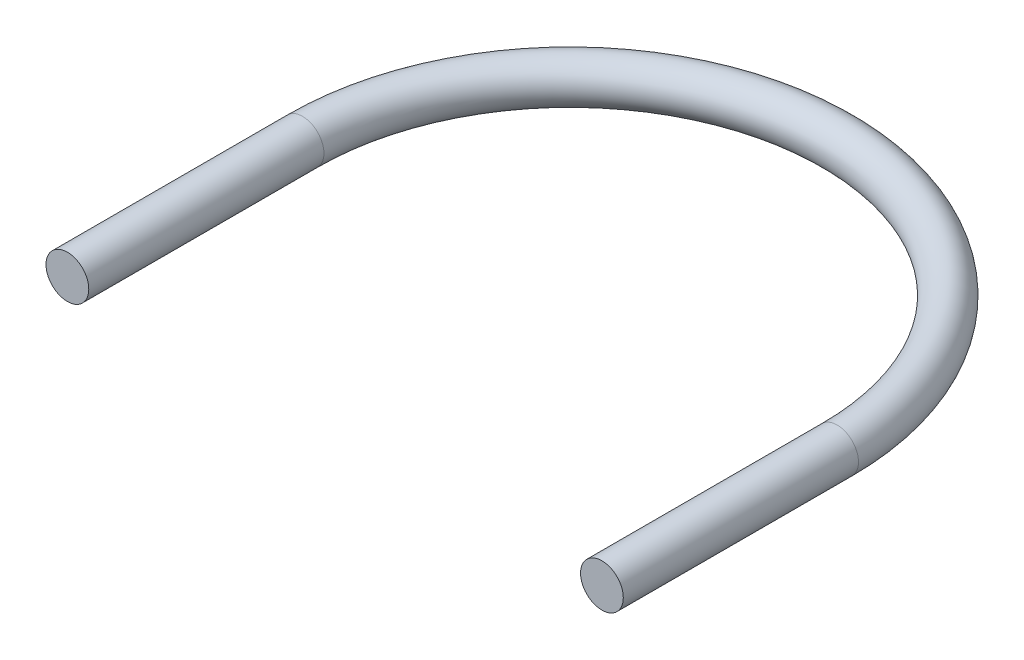
from build123d import *
from build123d.topology import SkipClean

# Parameters (mm, degrees)
SKETCH1_R                = 2.54
REVOLVE1_ANGLE           = 90
REVOLVE1_OTHER_WAY_ANGLE = 90
SKETCH2_R                = 2.54
BOSS_EXTRUDE1_DEPTH      = 27.94


with BuildPart() as part:
    # Sketch1 → Revolve1 (revolve)
    with BuildSketch(Plane(origin=(0, 0, 0), x_dir=(0, 0, -1), z_dir=(1, 0, 0))):
        Circle(SKETCH1_R)
    revolve(axis=Axis((0, -9.059790144, 31.75), (0, 1, 0)), revolution_arc=REVOLVE1_ANGLE)

    # Sketch1 → Revolve1 other way (revolve)
    with SkipClean():  # the faces are left unmerged after this step: merging them gives an invalid solid
        with BuildSketch(Plane(origin=(0, 0, 0), x_dir=(0, 0, -1), z_dir=(1, 0, 0))):
            Circle(SKETCH1_R)
        revolve(axis=Axis((0, -9.059790144, 31.75), (0, -1, 0)), revolution_arc=REVOLVE1_OTHER_WAY_ANGLE)

    # Sketch2 → Boss-Extrude1 (add)
    with SkipClean():  # the faces are left unmerged after this step: merging them gives an invalid solid
        with BuildSketch(Plane.XY.offset(31.75)):
            with Locations(Location((-31.75, 0, 0), (0, 0, 180))):
                Circle(SKETCH2_R)
            with Locations((31.75, 0)):
                Circle(SKETCH2_R)
        extrude(amount=BOSS_EXTRUDE1_DEPTH)


solid = part.part
